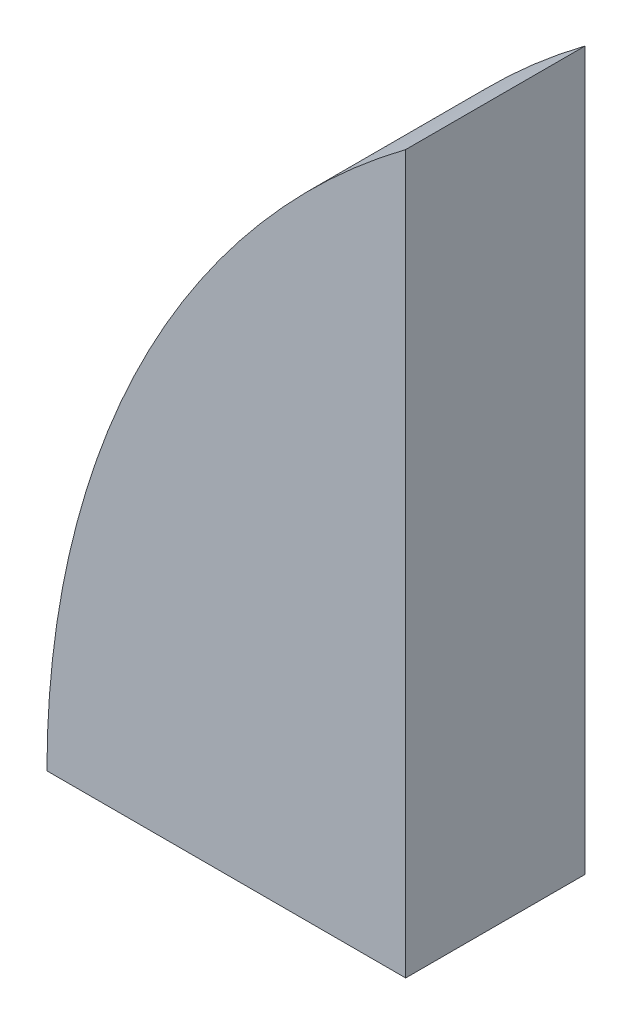
from build123d import *

# Parameters (mm, degrees)
BOSS_EXTRUDE1_DEPTH = 6.35


with BuildPart() as part:
    # Sketch1 → Boss-Extrude1 (new body)
    with BuildSketch(Plane.XY):
        with BuildLine():
            Line((0, 12.7), (6.35, 12.7))
            Line((6.35, 12.7), (12.7, 12.7))
            Line((12.7, 12.7), (12.7, 38.1))
            ThreePointArc((12.7, 38.1), (3.351936686, 26.899031657), (0, 12.7))
        make_face()
    extrude(amount=BOSS_EXTRUDE1_DEPTH)


solid = part.part
